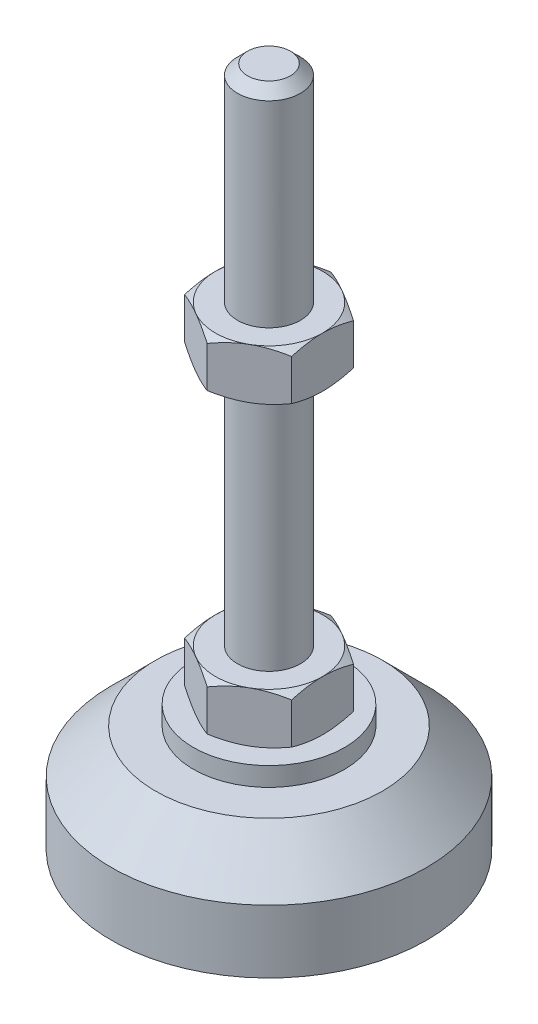
from build123d import *

# Parameters (mm, degrees)
EXTRUDE_1_DEPTH = 8
EXTRUDE_2_DEPTH = 8


with BuildPart() as part:
    # Эскиз1 → Повернуть1 (revolve)
    with BuildSketch(Plane.XY, mode=Mode.PRIVATE) as revolve_1_sk:
        Polygon((0, 0), (-25, 0), (-25, 10), (-18, 17), (-12, 17), (-12, 20), (-5, 20), (-5, 28), (-5, 106.4), (-3.4, 108), (0, 108), align=None)
    revolve(revolve_1_sk.sketch.rotate(Axis((0, 0, 0), (0, 1, 0)), 180), axis=Axis((0, 0, 0), (0, 1, 0)))  # turned: the seam where the file's is

    # Эскиз2 → Бобышка-Вытянуть1 (add)
    with BuildSketch(Plane(origin=(0, 20, 0), x_dir=(1, 0, 0), z_dir=(0, 1, 0))):
        Polygon((0, 9.814954576), (-8.5, 4.907477288), (-8.5, -4.907477288), (0, -9.814954576), (8.5, -4.907477288), (8.5, 4.907477288), align=None)
    extrude(amount=EXTRUDE_1_DEPTH)

    # Эскиз3 → Бобышка-Вытянуть2 (add)
    with BuildSketch(Plane(origin=(0, 67.2, 0), x_dir=(1, 0, 0), z_dir=(0, 1, 0))):
        Polygon((8.5, 4.907477288), (0, 9.814954576), (-8.5, 4.907477288), (-8.5, -4.907477288), (0, -9.814954576), (8.5, -4.907477288), align=None)
    extrude(amount=EXTRUDE_2_DEPTH)

    # Эскиз4 → Вырез-Повернуть2 (revolve, cut)
    with BuildSketch(Plane.XY, mode=Mode.PRIVATE) as cut_revolve_2_sk:
        Polygon((-15.42820323, 75.2), (-8.5, 75.2), (-15.42820323, 71.2), align=None)
        Polygon((-15.42820323, 67.2), (-15.42820323, 71.2), (-8.5, 67.2), align=None)
        Polygon((-15.42820323, 28), (-15.42820323, 24), (-8.5, 28), align=None)
        Polygon((-15.42820323, 24), (-15.42820323, 20), (-8.5, 20), align=None)
    revolve(cut_revolve_2_sk.sketch.rotate(Axis((0, 108, 0), (0, -1, 0)), 180), axis=Axis((0, 108, 0), (0, -1, 0)), mode=Mode.SUBTRACT)  # turned: the seam where the file's is


solid = part.part
